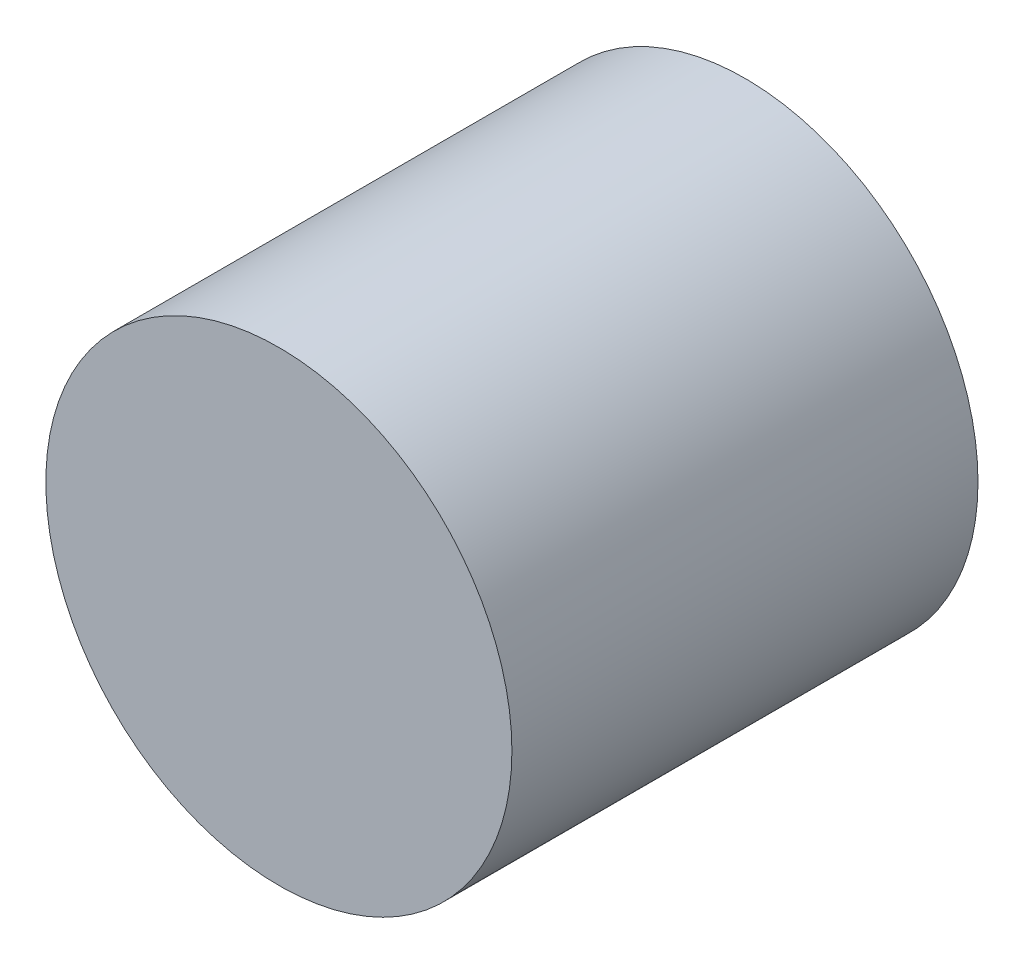
from build123d import *

# Parameters (mm, degrees)
SKETCH_1_R      = 5
EXTRUDE_1_DEPTH = 10


with BuildPart() as part:
    # 草图1 → 凸台-拉伸1 (new body)
    with BuildSketch(Plane.XY):
        with Locations((-7.212443888, 6.590681484)):
            Circle(SKETCH_1_R)
    extrude(amount=EXTRUDE_1_DEPTH)


solid = part.part
